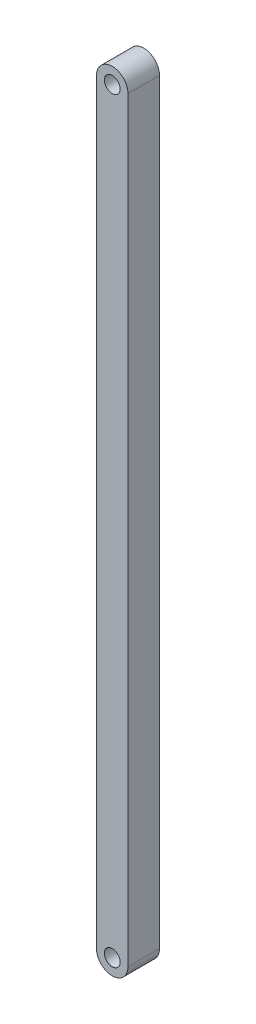
from build123d import *

# Parameters (mm, degrees)
BOSS_EXTRUDE1_DEPTH              = 20
F_10_0MM_DOWEL_HOLE1_D           = 10
F_10_0MM_DOWEL_HOLE1_DEPTH       = 20
F_10_0MM_DOWEL_HOLE1_CSINK_D     = 10.05
F_10_0MM_DOWEL_HOLE1_CSINK_ANGLE = 90


with BuildPart() as part:
    # Sketch1 → Boss-Extrude1 (new body)
    with BuildSketch(Plane.XY):
        with BuildLine():
            Line((0, 0), (0, 480))
            ThreePointArc((0, 480), (10, 490), (20, 480))
            Line((20, 480), (20, 0))
            ThreePointArc((20, 0), (10, -10), (0, 0))
        make_face()
    extrude(amount=BOSS_EXTRUDE1_DEPTH)

    # Ø10.0mm Dowel Hole1
    with Locations(Plane.XY.offset(20)):
        with Locations((10, 480), (10, 0)):
            CounterSinkHole(F_10_0MM_DOWEL_HOLE1_D / 2, F_10_0MM_DOWEL_HOLE1_CSINK_D / 2, depth=F_10_0MM_DOWEL_HOLE1_DEPTH, counter_sink_angle=F_10_0MM_DOWEL_HOLE1_CSINK_ANGLE)


solid = part.part
